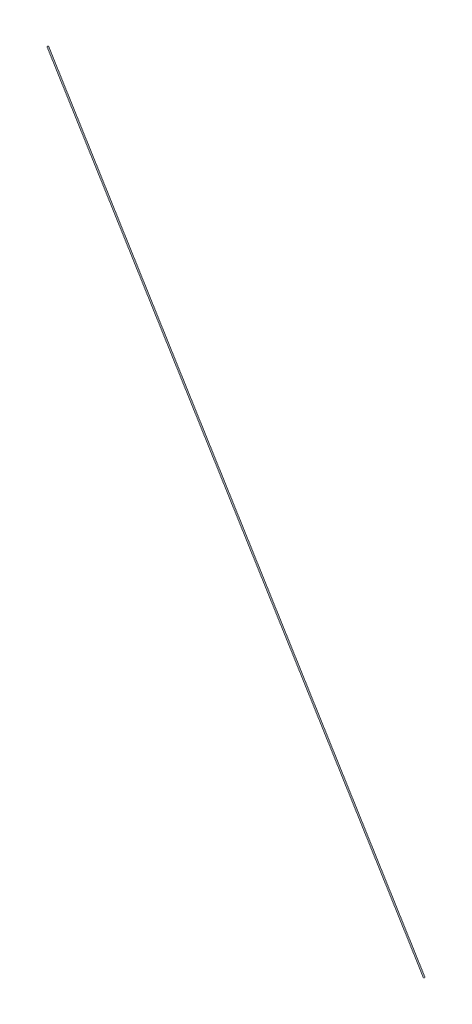
from build123d import *

# Parameters (mm, degrees)
SWEEP_1_PROFILE_R = 0.5


with BuildPart() as part:
    # 扫描1: sweep along a path in 草图2
    with BuildLine(Plane.XY) as sweep_1_path:
        Line((307.5, 0), (0, 505))
    # 扫描1 profile (on start of the path) → 扫描1 (sweep)
    with BuildSketch(Plane(origin=(307.5, 0, 0), x_dir=(0.854116895, 0.52008108, 0), z_dir=(-0.52008108, 0.854116895, 0))):
        Circle(SWEEP_1_PROFILE_R)
    sweep(path=sweep_1_path.line)


solid = part.part
